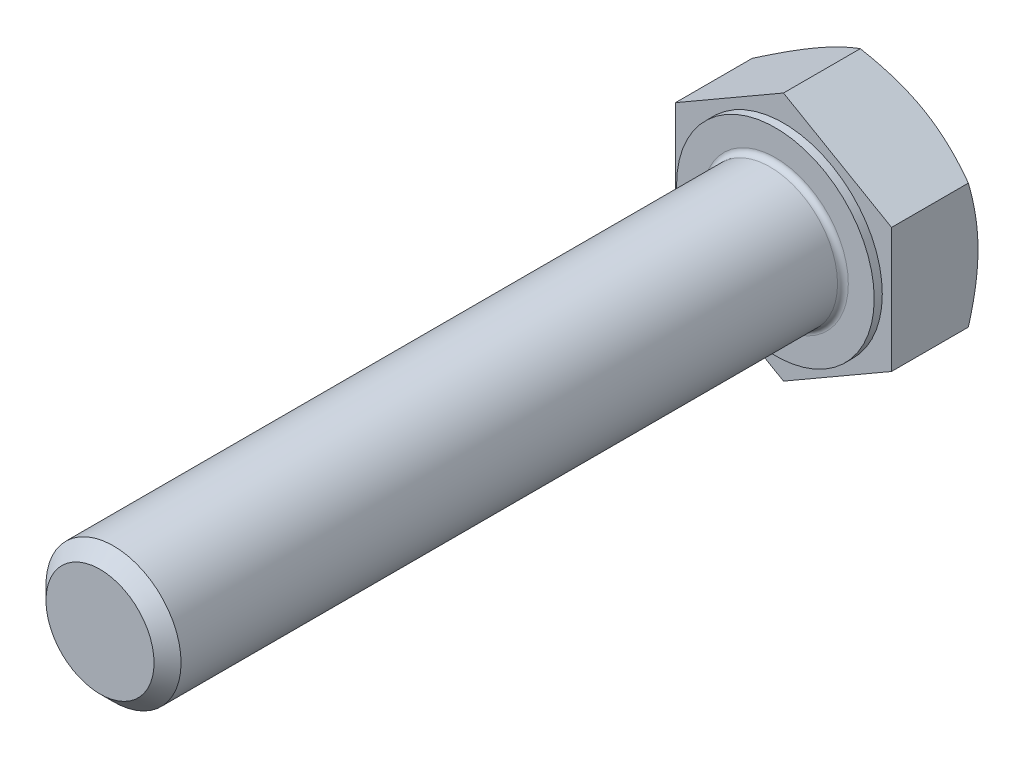
from build123d import *

# Parameters (mm, degrees)
VYSUNOUT1_DEPTH = 6.4
SKICA3_R        = 7.315
VYSUNOUT2_DEPTH = 0.6
SKICA4_R        = 5
VYSUNOUT3_DEPTH = 50
ZKOSIT1_SIZE    = 1
ZAOBLIT1_R      = 0.4


with BuildPart() as part:
    # Skica1 → Vysunout1 (new body)
    with BuildSketch(Plane.XY):
        Polygon((8, -4.618802154), (8, 4.618802154), (0, 9.237604307), (-8, 4.618802154), (-8, -4.618802154), (0, -9.237604307), align=None)
    extrude(amount=VYSUNOUT1_DEPTH)

    # Skica2 → Odebrat otočením1 (revolve, cut)
    with BuildSketch(Plane(origin=(0, 0, 0), x_dir=(1, 0, 0), z_dir=(0, 1, 0))):
        Polygon((8, 0), (19.085125168, 0), (19.085125168, -6.4), align=None)
    revolve(axis=Axis((0, 0, 0), (0, 0, 1)), mode=Mode.SUBTRACT)

    # Skica3 → Vysunout2 (add)
    with BuildSketch(Plane.XY.offset(6.4)):
        Circle(SKICA3_R)
    extrude(amount=VYSUNOUT2_DEPTH)

    # Skica4 → Vysunout3 (add)
    with BuildSketch(Plane.XY.offset(7)):
        Circle(SKICA4_R)
    extrude(amount=VYSUNOUT3_DEPTH)

    # Zkosit1
    zkosit1_edges = [part.edges().sort_by_distance(p)[0] for p in [
        (-5, 0, 57),
    ]]
    chamfer(zkosit1_edges, length=ZKOSIT1_SIZE)

    # Zaoblit1
    zaoblit1_edges = [part.edges().sort_by_distance(p)[0] for p in [
        (-5, 0, 7),
    ]]
    fillet(zaoblit1_edges, radius=ZAOBLIT1_R)


solid = part.part
